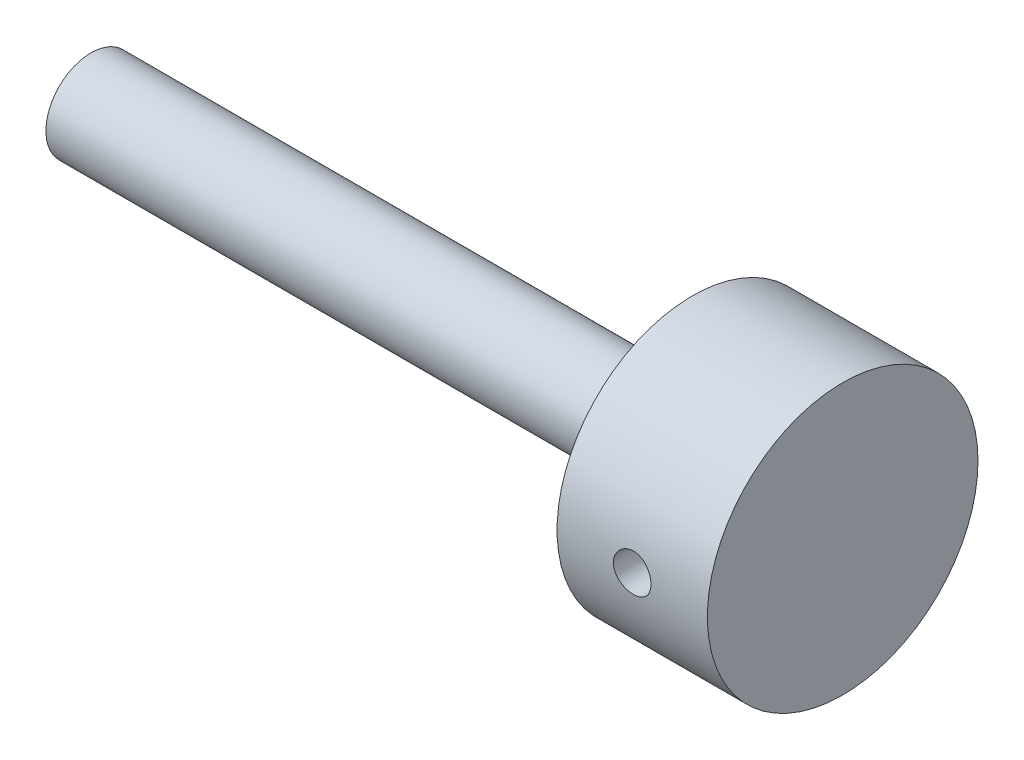
from build123d import *

# Parameters (mm, degrees)
IZIM2_R               = 2.5
KES_EKSTR_ZYON1_DEPTH = 52.5


with BuildPart() as part:
    # Çizim1 → Döndür1 (revolve)
    with BuildSketch(Plane.XY):
        Polygon((-20.235211, 0), (59.764789, 0), (59.764789, -12), (79.764789, -12), (79.764789, 0.241464104), (79.764789, 6), (-20.235211, 6), align=None)
    revolve(axis=Axis((79.764789, 6, 0), (-1, 0, 0)))

    # Çizim2 → Kes-Ekstrüzyon1 (cut, symmetric)
    with BuildSketch(Plane.XY):
        with Locations((69.76, 6)):
            Circle(IZIM2_R)
    extrude(amount=KES_EKSTR_ZYON1_DEPTH, both=True, mode=Mode.SUBTRACT)


solid = part.part
